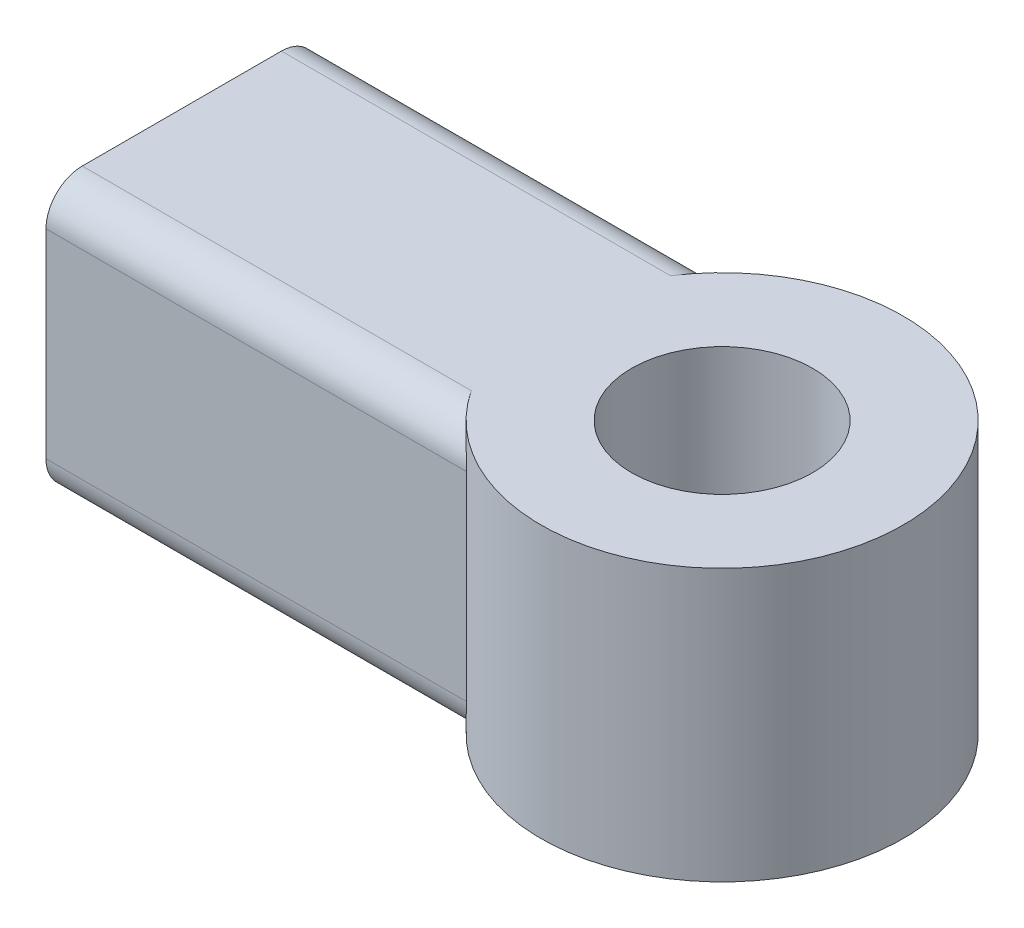
from build123d import *

# Parameters (mm, degrees)
SKETCH1_R           = 3.175
BOSS_EXTRUDE1_DEPTH = 9.525
FILLET1_R           = 1.27
SKETCH2_R           = 3.175
CUT_EXTRUDE1_DEPTH  = 12.7


with BuildPart() as part:
    # Sketch1 → Boss-Extrude1 (new body)
    with BuildSketch(Plane(origin=(0, 0, 0), x_dir=(1, 0, 0), z_dir=(0, 1, 0))):
        with BuildLine():
            Line((-4.200130206, -4.7625), (-18.948458917, -4.7625))
            Line((-18.948458917, -4.7625), (-18.948458917, 4.7625))
            Line((-18.948458917, 4.7625), (-4.200130206, 4.7625))
            ThreePointArc((-4.200130206, 4.7625), (6.35, 0), (-4.200130206, -4.7625))
        make_face()
        Circle(SKETCH1_R, mode=Mode.SUBTRACT)
    extrude(amount=BOSS_EXTRUDE1_DEPTH)

    # Fillet1
    fillet1_edges = [part.edges().sort_by_distance(p)[0] for p in [
        (-11.574294562, 9.525, -4.7625),
        (-11.574294562, 0, -4.7625),
        (-11.574294562, 0, 4.7625),
        (-11.574294562, 9.525, 4.7625),
    ]]
    fillet(fillet1_edges, radius=FILLET1_R)

    # Sketch2 → Cut-Extrude1 (cut)
    with BuildSketch(Plane.ZY.offset(18.948458917)):
        with Locations((0, 4.7625)):
            Circle(SKETCH2_R)
    extrude(amount=-CUT_EXTRUDE1_DEPTH, mode=Mode.SUBTRACT)


solid = part.part
